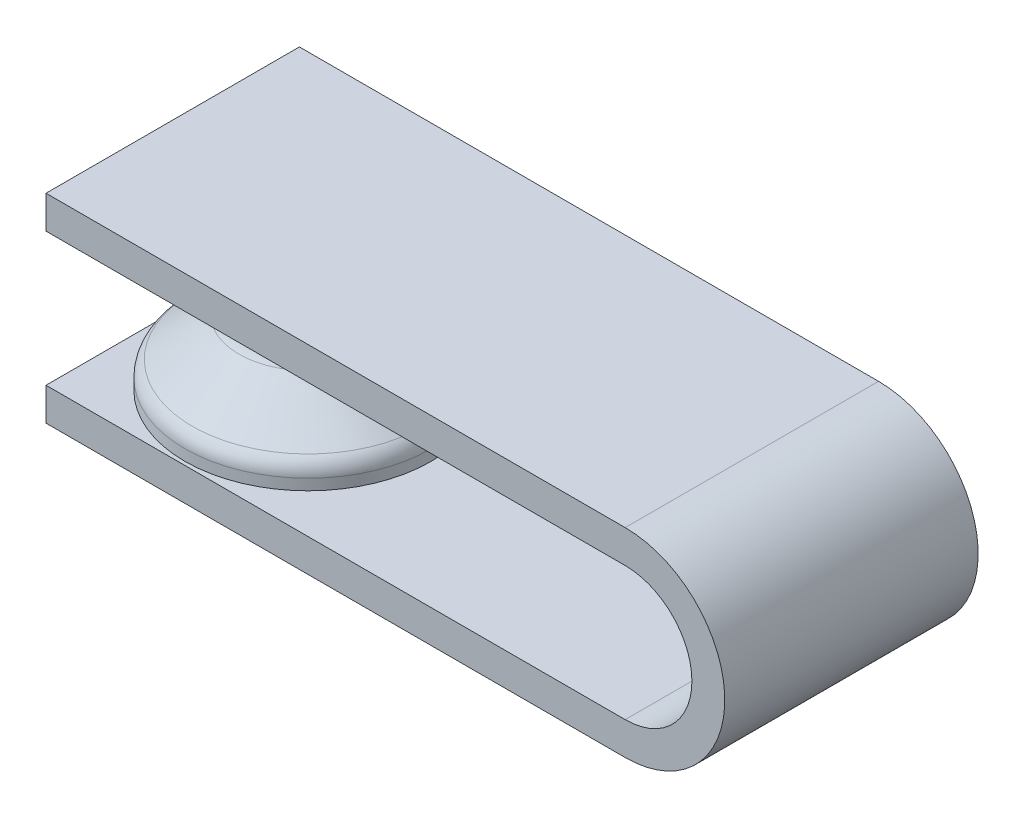
from build123d import *

# Parameters (mm, degrees)
FILLET1_R           = 1
SKETCH2_W           = 13.18647025
SKETCH2_H           = 12.34139231
BOSS_EXTRUDE1_DEPTH = 1.6
BOSS_EXTRUDE2_START = -6.5
SKETCH2_2_W         = 13.18647025
SKETCH2_2_H         = 12.34139231
BOSS_EXTRUDE2_DEPTH = 1.6
BOSS_EXTRUDE3_DEPTH = 12.341392


with BuildPart() as part:
    # Sketch1 → Revolve1 (revolve)
    with BuildSketch(Plane.XY):
        Polygon((-3, 5), (-3, 2.5), (-6, 0), (-6, -1), (0, -1), (0, 5), align=None)
    revolve(axis=Axis((0, -1, 0), (0, 1, 0)))

    # Fillet1
    fillet1_edges = [part.edges().sort_by_distance(p)[0] for p in [
        (3, 5, 0),
        (6, 0, 0),
        (3, 2.5, 0),
    ]]
    fillet(fillet1_edges, radius=FILLET1_R)

    # Sketch2 → Boss-Extrude1 (add)
    with BuildSketch(Plane.XZ.offset(1)):
        Rectangle(SKETCH2_W, SKETCH2_H)
    extrude(amount=BOSS_EXTRUDE1_DEPTH)



with BuildPart() as body_2:
    # Sketch2_2 → Boss-Extrude2 (new body)
    with BuildSketch(Plane.XZ.offset(1).offset(BOSS_EXTRUDE2_START)):
        Rectangle(SKETCH2_2_W, SKETCH2_2_H)
    extrude(amount=-BOSS_EXTRUDE2_DEPTH)


with BuildPart() as part_1:
    add(part.part)

    add(body_2.part)  # Boss-Extrude3 merges body 2
    # Sketch4 → Boss-Extrude3 (add)
    with BuildSketch(Plane.XY.offset(6.170696155)):
        with BuildLine():
            Line((6.593235125, 5.5), (21.616366257, 5.5))
            ThreePointArc((21.616366257, 5.5), (24.866366257, 2.25), (21.616366257, -1))
            Line((21.616366257, -1), (6.593235125, -1))
            Line((6.593235125, -1), (6.593235125, -2.6))
            Line((6.593235125, -2.6), (21.616366257, -2.6))
            ThreePointArc((21.616366257, -2.6), (26.466366257, 2.25), (21.616366257, 7.1))
            Line((21.616366257, 7.1), (6.593235125, 7.1))
            Line((6.593235125, 7.1), (6.593235125, 5.5))
        make_face()
    extrude(amount=-BOSS_EXTRUDE3_DEPTH)


solid = part_1.part
